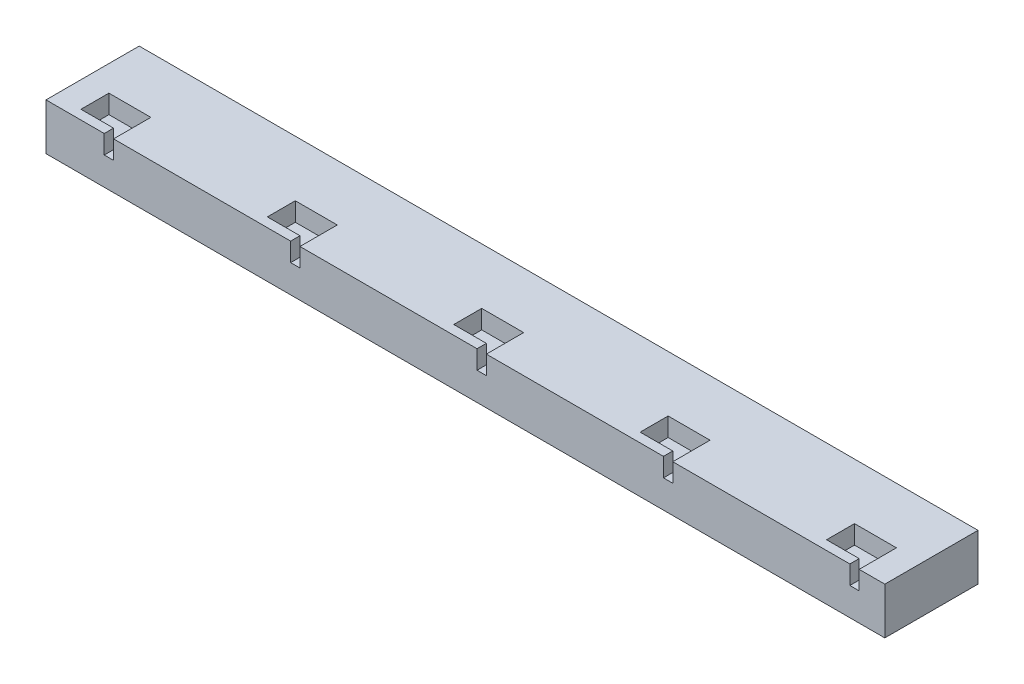
from build123d import *

# Parameters (mm, degrees)
SKETCH1_W           = 180
SKETCH1_H           = 20
BOSS_EXTRUDE1_DEPTH = 10
CUT_EXTRUDE2_DEPTH  = 4


with BuildPart() as part:
    # Sketch1 → Boss-Extrude1 (new body)
    with BuildSketch(Plane(origin=(0, 0, 0), x_dir=(1, 0, 0), z_dir=(0, 1, 0))):
        Rectangle(SKETCH1_W, SKETCH1_H)
    extrude(amount=BOSS_EXTRUDE1_DEPTH)

    # Sketch2 → Cut-Extrude2 (cut)
    with BuildSketch(Plane(origin=(0, 10, 0), x_dir=(1, 0, 0), z_dir=(0, 1, 0))):
        Polygon((84.5, -2), (84.5, -7.781340665), (84.5, -10), (82.5, -10), (82.5, -8), (75.5, -8), (75.5, -2), align=None)
        Polygon((44.5, -2), (44.5, -7.781340665), (44.5, -10), (42.5, -10), (42.5, -8), (35.5, -8), (35.5, -2), align=None)
        Polygon((4.5, -2), (4.5, -7.781340665), (4.5, -10), (2.5, -10), (2.5, -8), (-4.5, -8), (-4.5, -2), align=None)
        Polygon((-35.5, -2), (-35.5, -7.781340665), (-35.5, -10), (-37.5, -10), (-37.5, -8), (-44.5, -8), (-44.5, -2), align=None)
        Polygon((-75.5, -2), (-75.5, -7.781340665), (-75.5, -10), (-77.5, -10), (-77.5, -8), (-84.5, -8), (-84.5, -2), align=None)
    extrude(amount=-CUT_EXTRUDE2_DEPTH, mode=Mode.SUBTRACT)


solid = part.part
